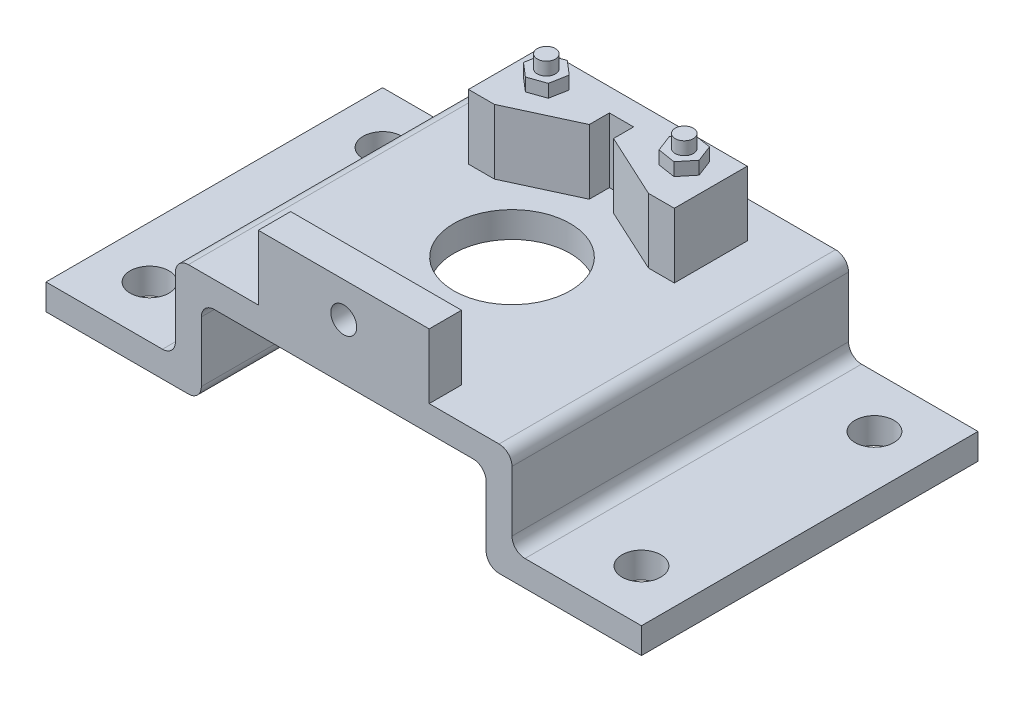
from build123d import *

# Parameters (mm, degrees)
EXTRUDE_1_DEPTH     = 130
FILLET_1_R          = 10
SKETCH_2_R          = 45
CUT_EXTRUDE_1_DEPTH = 260
SKETCH_3_R          = 7
EXTRUDE_2_DEPTH     = 50
SKETCH_4_R          = 7
EXTRUDE_3_DEPTH     = 10
SKETCH_5_R          = 7
EXTRUDE_4_DEPTH     = 70
SKETCH_6_W          = 132
SKETCH_6_H          = 25
EXTRUDE_5_DEPTH     = 50
SKETCH_7_R          = 10
CUT_EXTRUDE_2_DEPTH = 50
SKETCH_8_R          = 15
CUT_EXTRUDE_3_DEPTH = 30


with BuildPart() as part:
    # 草图1 → 凸台-拉伸1 (new body, symmetric)
    with BuildSketch(Plane.XY):
        Polygon((0, 0), (0, 20), (-130, 20), (-130, 10.839517471), (-130, -46.598965425), (-230, -46.598965425), (-230, -66.598965425), (-110, -66.598965425), (-110, 0), align=None)
        Polygon((130, 20), (0, 20), (0, 0), (110, 0), (110, -66.598965425), (230, -66.598965425), (230, -46.598965425), (130, -46.598965425), (130, 10.839517471), align=None)
    extrude(amount=EXTRUDE_1_DEPTH, both=True)

    # 圆角1
    fillet_1_edges = [part.edges().sort_by_distance(p)[0] for p in [
        (-130, 20, 0),
        (130, 20, 0),
        (130, -46.598965425, 0),
        (110, -66.598965425, 0),
        (110, 0, 0),
        (-110, 0, 0),
        (-110, -66.598965425, 0),
        (-130, -46.598965425, 0),
    ]]
    fillet(fillet_1_edges, radius=FILLET_1_R)

    # 草图2 → 切除-拉伸1 (cut)
    with BuildSketch(Plane(origin=(0, 20, 0), x_dir=(1, 0, 0), z_dir=(0, 1, 0))):
        Circle(SKETCH_2_R)
    extrude(amount=-CUT_EXTRUDE_1_DEPTH, mode=Mode.SUBTRACT)

    # 草图3 → 凸台-拉伸2 (add)
    with BuildSketch(Plane(origin=(0, 20, 0), x_dir=(1, 0, 0), z_dir=(0, 1, 0))):
        Polygon((79.997030901, 101.745041166), (0.475713007, 101.745041166), (0.475713007, 84.097255875), (9.839462373, 84.097255875), (9.839462373, 68.604224939), (59.997030901, 45.412205859), (79.997030901, 45.412205859), align=None)
        with Locations((53.744497978, 79.333035198)):
            Circle(SKETCH_3_R, mode=Mode.SUBTRACT)
        Polygon((-79.045604886, 45.412205859), (-59.045604886, 45.412205859), (-27.699569626, 59.906087225), (-8.888036358, 68.604224939), (-8.888036358, 84.097255875), (0.475713007, 84.097255875), (0.475713007, 101.745041166), (-79.045604886, 101.745041166), align=None)
        with Locations((-52.793071964, 79.333035198)):
            Circle(SKETCH_3_R, mode=Mode.SUBTRACT)
    extrude(amount=EXTRUDE_2_DEPTH)

    # 草图4 → 凸台-拉伸3 (add)
    with BuildSketch(Plane(origin=(0, 70, 0), x_dir=(1, 0, 0), z_dir=(0, 1, 0))):
        Polygon((48.795631933, 92.27555137), (40.061517162, 81.518449569), (45.010383207, 68.575933397), (58.693364024, 66.390519026), (67.427478795, 77.147620827), (62.47861275, 90.090136999), align=None)
        with Locations((53.744497978, 79.333035198)):
            Circle(SKETCH_4_R, mode=Mode.SUBTRACT)
        Polygon((-50.227927921, 92.949937784), (-63.303083503, 88.362966397), (-65.868227546, 74.746063811), (-55.358216006, 65.716132612), (-42.283060425, 70.303104), (-39.717916382, 83.920006586), align=None)
        with Locations((-52.793071964, 79.333035198)):
            Circle(SKETCH_4_R, mode=Mode.SUBTRACT)
    extrude(amount=EXTRUDE_3_DEPTH)

    # 草图5 → 凸台-拉伸4 (add)
    with BuildSketch(Plane(origin=(0, 20, 0), x_dir=(1, 0, 0), z_dir=(0, 1, 0))):
        with Locations((53.744497978, 79.333035198)):
            Circle(SKETCH_5_R)
        with Locations((-52.793071964, 79.333035198)):
            Circle(SKETCH_5_R)
    extrude(amount=EXTRUDE_4_DEPTH)

    # 草图6 → 凸台-拉伸5 (add)
    with BuildSketch(Plane(origin=(0, 20, 0), x_dir=(1, 0, 0), z_dir=(0, 1, 0))):
        with Locations((0, -117.5)):
            Rectangle(SKETCH_6_W, SKETCH_6_H)
    extrude(amount=EXTRUDE_5_DEPTH)

    # 草图7 → 切除-拉伸2 (cut)
    with BuildSketch(Plane.XY.offset(130)):
        with Locations((0, 43.080261377)):
            Circle(SKETCH_7_R)
    extrude(amount=-CUT_EXTRUDE_2_DEPTH, mode=Mode.SUBTRACT)

    # 草图8 → 切除-拉伸3 (cut)
    with BuildSketch(Plane(origin=(0, -46.598965425, 0), x_dir=(1, 0, 0), z_dir=(0, 1, 0))):
        with Locations((190, 90)):
            Circle(SKETCH_8_R)
        with Locations((190, -90)):
            Circle(SKETCH_8_R)
        with Locations((-190, -90)):
            Circle(SKETCH_8_R)
        with Locations((-190, 90)):
            Circle(SKETCH_8_R)
    extrude(amount=-CUT_EXTRUDE_3_DEPTH, mode=Mode.SUBTRACT)


solid = part.part
